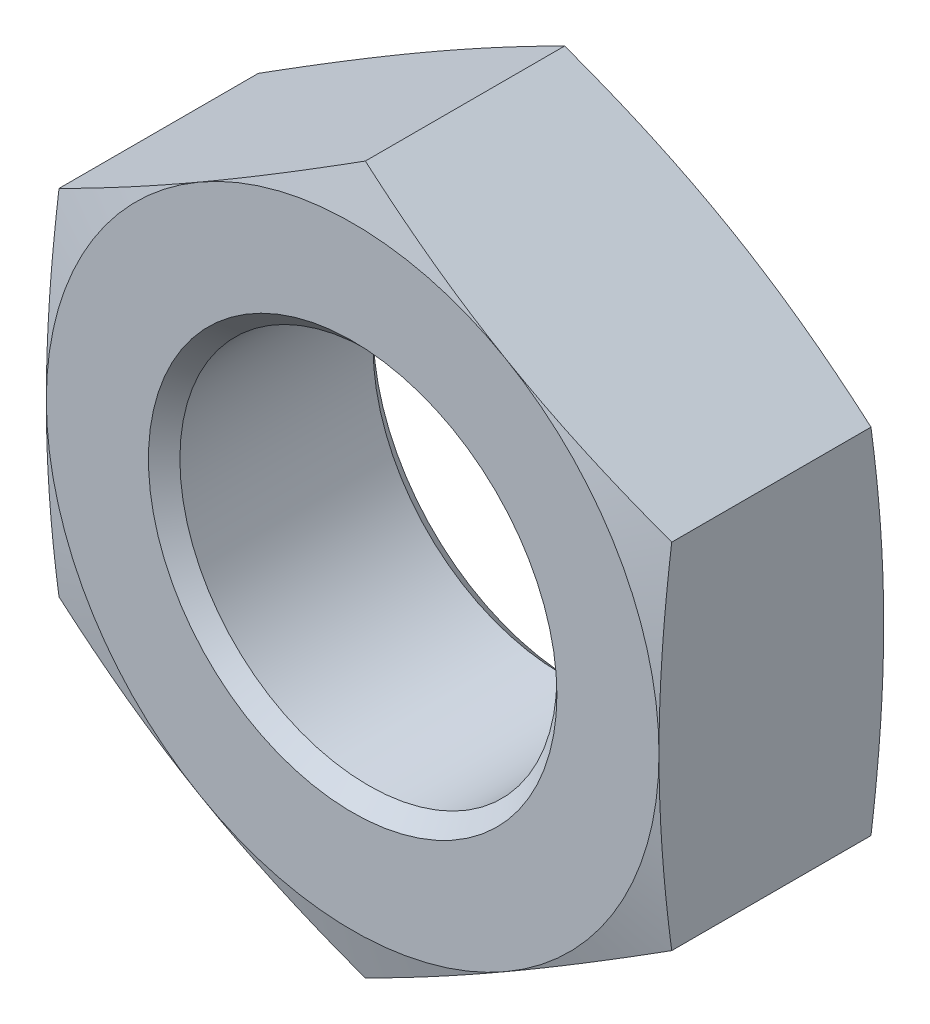
from build123d import *

# Parameters (mm, degrees)
SKETCH2_W          = 76.2
SKETCH2_H          = 76.2
CUT_EXTRUDE1_DEPTH = 13.97


with BuildPart() as part:
    # Sketch1 → Revolve1 (revolve)
    with BuildSketch(Plane(origin=(0, 0, 0), x_dir=(0, 0, -1), z_dir=(1, 0, 0))):
        Polygon((0, 0), (0, 19.05), (1.020886423, 22.86), (12.949113577, 22.86), (13.97, 19.05), (13.97, 0), align=None)
    revolve(axis=Axis((0, 0, -13.97), (0, 0, 1)))

    # Sketch2 → Cut-Extrude1 (cut)
    with BuildSketch(Plane.XY):
        Rectangle(SKETCH2_W, SKETCH2_H)
        Polygon((-19.05, 10.998522628), (-19.05, -10.998522628), (0, -21.997045256), (19.05, -10.998522628), (19.05, 10.998522628), (0, 21.997045256), align=None, mode=Mode.SUBTRACT)
    extrude(amount=-CUT_EXTRUDE1_DEPTH, mode=Mode.SUBTRACT)

    # Sketch3 → Cut-Revolve1 (revolve, cut)
    with BuildSketch(Plane(origin=(0, 0, 0), x_dir=(0, 0, -1), z_dir=(1, 0, 0))):
        Polygon((0, 0), (0, 12.7), (0.9779, 11.7221), (12.9921, 11.7221), (13.97, 12.7), (13.97, 0), align=None)
    revolve(axis=Axis((0, 0, -13.97), (0, 0, 1)), mode=Mode.SUBTRACT)


solid = part.part
